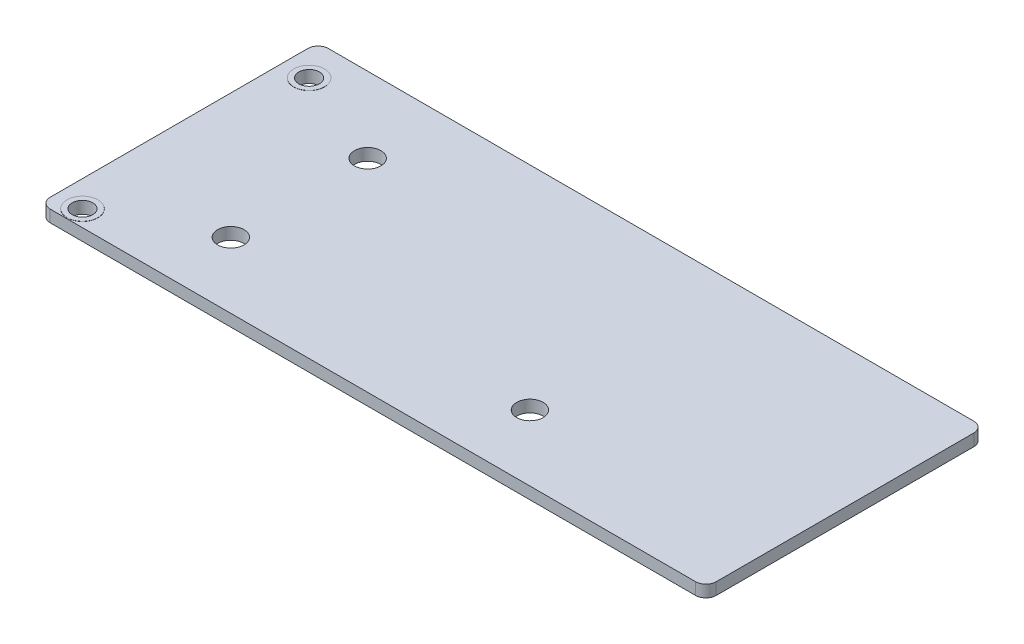
from build123d import *

# Parameters (mm, degrees)
SKETCH1_W                = 64.65
SKETCH1_H                = 27
BOSS_EXTRUDE1_DEPTH      = 1.16
FILLET1_R                = 1
SKETCH2_R                = 1
SKETCH2_R_2              = 1.285
CUT_EXTRUDE1_DEPTH       = 2.16
SKETCH3_R                = 1.5
SKETCH3_R_2              = 1
BOSS_EXTRUDE2_DEPTH      = 0.015
BOSS_EXTRUDE2_DEPTH_BACK = 1.165


with BuildPart() as part:
    # Sketch1 → Boss-Extrude1 (new body)
    with BuildSketch(Plane(origin=(0, 0, 0), x_dir=(1, 0, 0), z_dir=(0, 1, 0))):
        Rectangle(SKETCH1_W, SKETCH1_H)
    extrude(amount=BOSS_EXTRUDE1_DEPTH)

    # Fillet1
    fillet1_edges = [part.edges().sort_by_distance(p)[0] for p in [
        (32.325, 0.58, 13.5),
        (-32.325, 0.58, 13.5),
        (-32.325, 0.58, -13.5),
        (32.325, 0.58, -13.5),
    ]]
    fillet(fillet1_edges, radius=FILLET1_R)

    # Sketch2 → Cut-Extrude1 (cut, through all)
    with BuildSketch(Plane(origin=(0, 1.16, 0), x_dir=(1, 0, 0), z_dir=(0, 1, 0))):
        with Locations((-29.775, -11.92)):
            Circle(SKETCH2_R)
        with Locations((-29.775, 10.08)):
            Circle(SKETCH2_R)
        with Locations((-20.19, -7.105)):
            Circle(SKETCH2_R_2)
        with Locations((-20.19, 6.18)):
            Circle(SKETCH2_R_2)
        with Locations((8.845, -7.105)):
            Circle(SKETCH2_R_2)
    extrude(amount=-CUT_EXTRUDE1_DEPTH, mode=Mode.SUBTRACT)

    # Sketch3 → Boss-Extrude2 (add, two sides)
    with BuildSketch(Plane(origin=(0, 1.16, 0), x_dir=(1, 0, 0), z_dir=(0, 1, 0))) as boss_extrude2_sk:
        with Locations((-29.775, -11.92)):
            Circle(SKETCH3_R)
        with Locations((-29.775, -11.92)):
            Circle(SKETCH3_R_2, mode=Mode.SUBTRACT)
        with Locations((-29.775, 10.08)):
            Circle(SKETCH3_R)
        with Locations((-29.775, 10.08)):
            Circle(SKETCH3_R_2, mode=Mode.SUBTRACT)
    extrude(amount=BOSS_EXTRUDE2_DEPTH)
    extrude(boss_extrude2_sk.sketch, amount=-BOSS_EXTRUDE2_DEPTH_BACK)


solid = part.part
